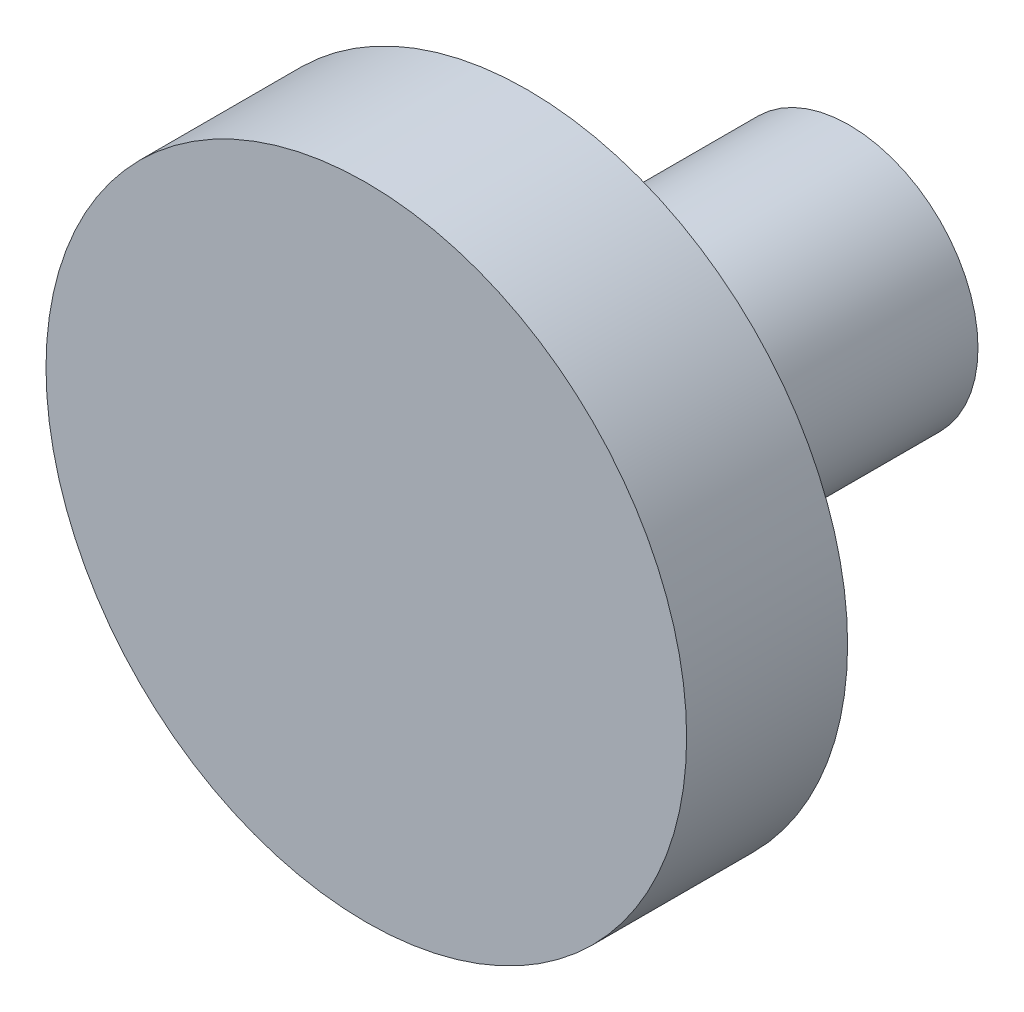
from build123d import *

# Parameters (mm, degrees)
SKETCH1_R           = 9.95
BOSS_EXTRUDE1_DEPTH = 5
SKETCH2_R           = 4
BOSS_EXTRUDE2_DEPTH = 10


with BuildPart() as part:
    # Sketch1 → Boss-Extrude1 (new body)
    with BuildSketch(Plane.XY):
        Circle(SKETCH1_R)
    extrude(amount=BOSS_EXTRUDE1_DEPTH)

    # Sketch2 → Boss-Extrude2 (add)
    with BuildSketch(Plane(origin=(0, 0, 0), x_dir=(-1, 0, 0), z_dir=(0, 0, -1))):
        Circle(SKETCH2_R)
    extrude(amount=BOSS_EXTRUDE2_DEPTH)


solid = part.part
